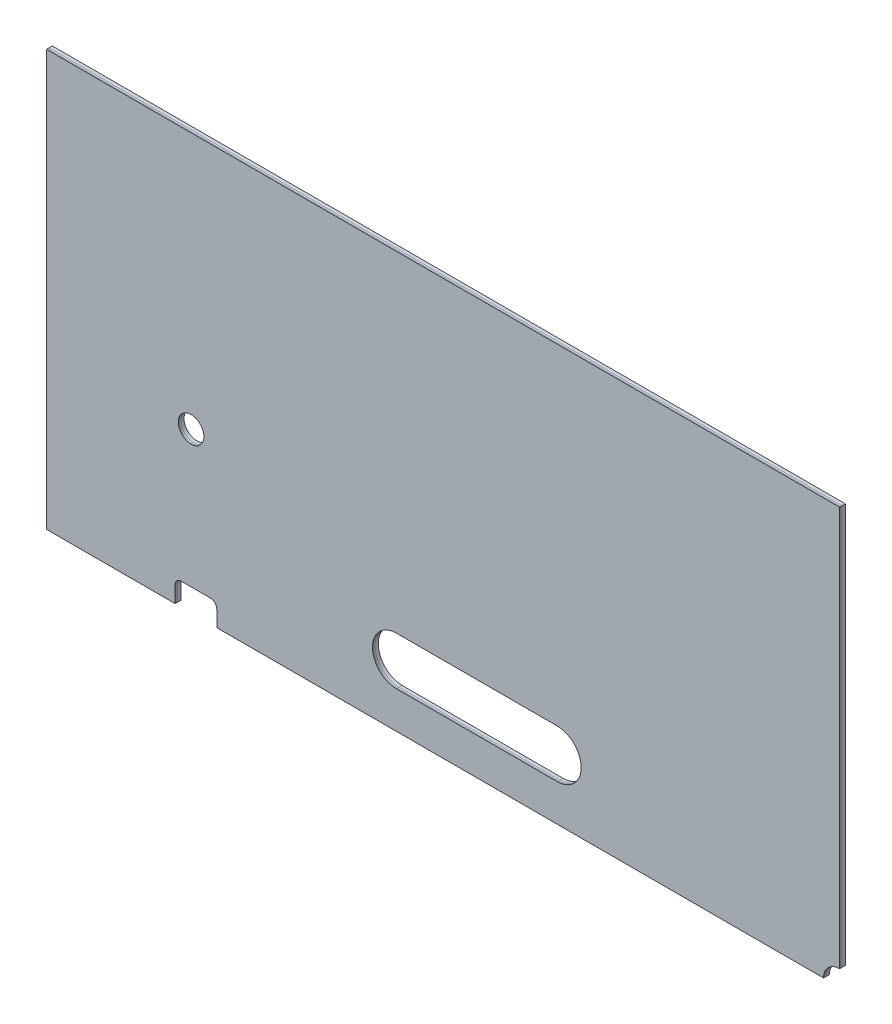
from build123d import *

# Parameters (mm, degrees)
SZKIC1_W                    = 247
SZKIC1_H                    = 129.5
DODANIE_WYCI_GNI_CIE1_DEPTH = 1
SZKIC2_W                    = 247
SZKIC2_H                    = 129.5
DODANIE_WYCI_GNI_CIE2_DEPTH = 0.5
SZKIC3_W                    = 247
SZKIC3_H                    = 129.5
DODANIE_WYCI_GNI_CIE3_DEPTH = 0.3
WYTNIJ_WYCI_GNI_CIE2_DEPTH  = 2.8
WYTNIJ_WYCI_GNI_CIE3_DEPTH  = 2.8
SZKIC8_W                    = 13
SZKIC8_H                    = 7
WYTNIJ_WYCI_GNI_CIE4_DEPTH  = 2.8
ZAOKR_GLENIE1_R             = 2
ZAOKR_GLENIE2_R             = 2
ZAOKR_GLENIE3_R             = 2
SZKIC9_R                    = 4
WYTNIJ_WYCI_GNI_CIE5_DEPTH  = 2.8


with BuildPart() as part:
    # Szkic1 → Dodanie-wyciągnięcie1 (new body)
    with BuildSketch(Plane.XY):
        with Locations((-123.5, 64.75)):
            Rectangle(SZKIC1_W, SZKIC1_H)
    extrude(amount=DODANIE_WYCI_GNI_CIE1_DEPTH)


with BuildPart() as body_2:
    # Szkic2 → Dodanie-wyciągnięcie2 (new body)
    with BuildSketch(Plane.XY.offset(1)):
        with Locations((-123.5, 64.75)):
            Rectangle(SZKIC2_W, SZKIC2_H)
    extrude(amount=DODANIE_WYCI_GNI_CIE2_DEPTH)


with BuildPart() as body_3:
    # Szkic3 → Dodanie-wyciągnięcie3 (new body)
    with BuildSketch(Plane.XY.offset(1.5)):
        with Locations((-123.5, 64.75)):
            Rectangle(SZKIC3_W, SZKIC3_H)
    extrude(amount=DODANIE_WYCI_GNI_CIE3_DEPTH)


with BuildPart() as wytnij_wyci_gni_cie2_tool:
    # Szkic5 → Wytnij-wyciągnięcie2 (new body, through all)
    with BuildSketch(Plane.XY.offset(1.8)):
        with BuildLine():
            Line((-138, 26.5), (-88, 26.5))
            ThreePointArc((-88, 26.5), (-80.5, 19), (-88, 11.5))
            Line((-88, 11.5), (-138, 11.5))
            ThreePointArc((-138, 11.5), (-145.5, 19), (-138, 26.5))
        make_face()
    extrude(amount=-WYTNIJ_WYCI_GNI_CIE2_DEPTH)


with BuildPart() as part_1:
    add(part.part)

    # Wytnij-wyciągnięcie2: cut by wytnij_wyci_gni_cie2_tool
    add(wytnij_wyci_gni_cie2_tool.part, mode=Mode.SUBTRACT)


with BuildPart() as body_2_1:
    add(body_2.part)

    # Wytnij-wyciągnięcie2: cut by wytnij_wyci_gni_cie2_tool
    add(wytnij_wyci_gni_cie2_tool.part, mode=Mode.SUBTRACT)


with BuildPart() as body_3_1:
    add(body_3.part)

    # Wytnij-wyciągnięcie2: cut by wytnij_wyci_gni_cie2_tool
    add(wytnij_wyci_gni_cie2_tool.part, mode=Mode.SUBTRACT)


with BuildPart() as wytnij_wyci_gni_cie3_tool:
    # Szkic6 → Wytnij-wyciągnięcie3 (new body, through all)
    with BuildSketch(Plane.XY.offset(1.8)):
        with BuildLine():
            Line((0, 0), (-5, 0))
            ThreePointArc((-5, 0), (-3.535533906, 3.535533906), (0, 5))
            Line((0, 5), (0, 0))
        make_face()
    extrude(amount=-WYTNIJ_WYCI_GNI_CIE3_DEPTH)


with BuildPart() as part_2:
    add(part_1.part)

    # Wytnij-wyciągnięcie3: cut by wytnij_wyci_gni_cie3_tool
    add(wytnij_wyci_gni_cie3_tool.part, mode=Mode.SUBTRACT)


with BuildPart() as body_2_2:
    add(body_2_1.part)

    # Wytnij-wyciągnięcie3: cut by wytnij_wyci_gni_cie3_tool
    add(wytnij_wyci_gni_cie3_tool.part, mode=Mode.SUBTRACT)


with BuildPart() as body_3_2:
    add(body_3_1.part)

    # Wytnij-wyciągnięcie3: cut by wytnij_wyci_gni_cie3_tool
    add(wytnij_wyci_gni_cie3_tool.part, mode=Mode.SUBTRACT)


with BuildPart() as wytnij_wyci_gni_cie4_tool:
    # Szkic8 → Wytnij-wyciągnięcie4 (new body, through all)
    with BuildSketch(Plane.XY.offset(1.8)):
        with Locations((-200.5, 3.5)):
            Rectangle(SZKIC8_W, SZKIC8_H)
    extrude(amount=-WYTNIJ_WYCI_GNI_CIE4_DEPTH)


with BuildPart() as part_3:
    add(part_2.part)

    # Wytnij-wyciągnięcie4: cut by wytnij_wyci_gni_cie4_tool
    add(wytnij_wyci_gni_cie4_tool.part, mode=Mode.SUBTRACT)

    # Zaokrąglenie1
    zaokr_glenie1_edges = [part_3.edges().sort_by_distance(p)[0] for p in [
        (-207, 7, 0.5),
        (-194, 7, 0.5),
    ]]
    fillet(zaokr_glenie1_edges, radius=ZAOKR_GLENIE1_R)


with BuildPart() as body_2_3:
    add(body_2_2.part)

    # Wytnij-wyciągnięcie4: cut by wytnij_wyci_gni_cie4_tool
    add(wytnij_wyci_gni_cie4_tool.part, mode=Mode.SUBTRACT)

    # Zaokrąglenie2
    zaokr_glenie2_edges = [body_2_3.edges().sort_by_distance(p)[0] for p in [
        (-207, 7, 1.25),
        (-194, 7, 1.25),
    ]]
    fillet(zaokr_glenie2_edges, radius=ZAOKR_GLENIE2_R)


with BuildPart() as body_3_3:
    add(body_3_2.part)

    # Wytnij-wyciągnięcie4: cut by wytnij_wyci_gni_cie4_tool
    add(wytnij_wyci_gni_cie4_tool.part, mode=Mode.SUBTRACT)

    # Zaokrąglenie3
    zaokr_glenie3_edges = [body_3_3.edges().sort_by_distance(p)[0] for p in [
        (-207, 7, 1.65),
        (-194, 7, 1.65),
    ]]
    fillet(zaokr_glenie3_edges, radius=ZAOKR_GLENIE3_R)


with BuildPart() as wytnij_wyci_gni_cie5_tool:
    # Szkic9 → Wytnij-wyciągnięcie5 (new body, through all)
    with BuildSketch(Plane.XY.offset(1.8)):
        with Locations((-202, 49.5)):
            Circle(SZKIC9_R)
    extrude(amount=-WYTNIJ_WYCI_GNI_CIE5_DEPTH)


with BuildPart() as part_4:
    add(part_3.part)

    # Wytnij-wyciągnięcie5: cut by wytnij_wyci_gni_cie5_tool
    add(wytnij_wyci_gni_cie5_tool.part, mode=Mode.SUBTRACT)


with BuildPart() as body_2_4:
    add(body_2_3.part)

    # Wytnij-wyciągnięcie5: cut by wytnij_wyci_gni_cie5_tool
    add(wytnij_wyci_gni_cie5_tool.part, mode=Mode.SUBTRACT)


with BuildPart() as body_3_4:
    add(body_3_3.part)

    # Wytnij-wyciągnięcie5: cut by wytnij_wyci_gni_cie5_tool
    add(wytnij_wyci_gni_cie5_tool.part, mode=Mode.SUBTRACT)


solid = Compound([part_4.part, body_2_4.part, body_3_4.part])
